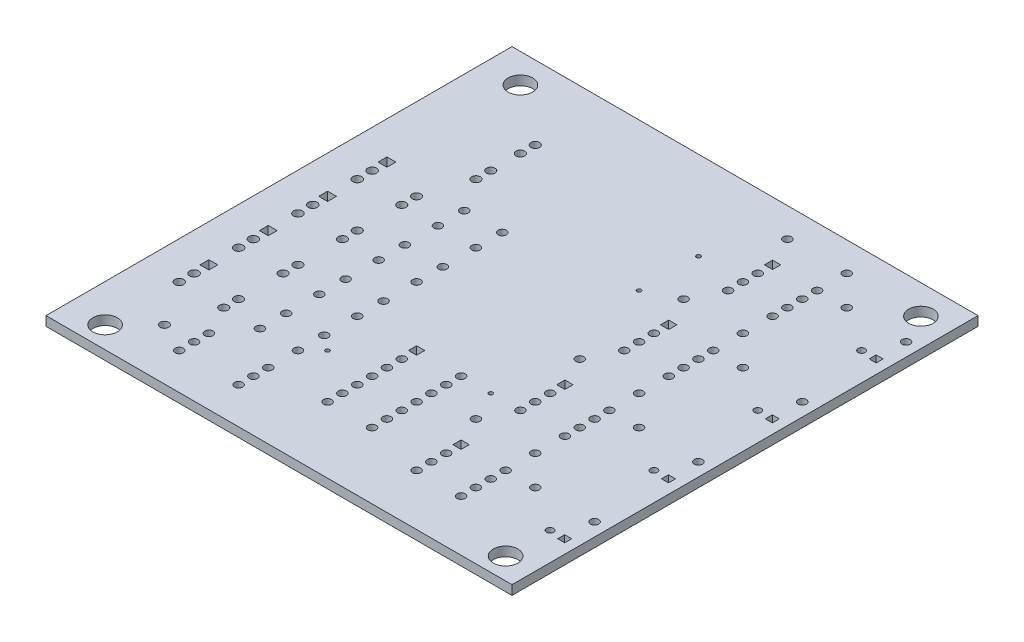
from build123d import *

# Parameters (mm, degrees)
SKETCH1_W           = 79.896668375
SKETCH1_H           = 79.896668375
SKETCH1_R           = 0.699373125
SKETCH1_R_2         = 0.60075445
SKETCH1_R_3         = 0.7629525
SKETCH1_R_4         = 0.73752075
SKETCH1_R_5         = 0.350436799
SKETCH1_R_6         = 2.102626446
SKETCH1_W_2         = 1.39874625
SKETCH1_H_2         = 1.39874625
SKETCH1_W_3         = 1.525905
SKETCH1_H_3         = 1.525905
SKETCH1_W_4         = 1.2015089
SKETCH1_H_4         = 1.2015089
BOSS_EXTRUDE1_DEPTH = 1.6


with BuildPart() as part:
    # Sketch1 → Boss-Extrude1 (new body)
    with BuildSketch(Plane(origin=(0, 1.6, 0), x_dir=(1, 0, 0), z_dir=(0, 1, 0))):
        with Locations((40.050061187, -40.050061187)):
            Rectangle(SKETCH1_W, SKETCH1_H)
        with Locations((26.874260053, -48.901779577)):
            Circle(SKETCH1_R, mode=Mode.SUBTRACT)
        with Locations((54.849220375, -53.407381437)):
            Circle(SKETCH1_R, mode=Mode.SUBTRACT)
        with Locations((26.874260053, -53.407522725)):
            Circle(SKETCH1_R, mode=Mode.SUBTRACT)
        with Locations((75.194408444, -50.864135794)):
            Circle(SKETCH1_R_2, mode=Mode.SUBTRACT)
        with Locations((77.737795375, -45.777856437)):
            Circle(SKETCH1_R, mode=Mode.SUBTRACT)
        with Locations((62.478745375, -40.691506438)):
            Circle(SKETCH1_R, mode=Mode.SUBTRACT)
        with Locations((52.306045375, -40.691506438)):
            Circle(SKETCH1_R, mode=Mode.SUBTRACT)
        with Locations((62.478745375, -53.407381437)):
            Circle(SKETCH1_R, mode=Mode.SUBTRACT)
        with Locations((6.528824731, -61.036906438)):
            Circle(SKETCH1_R_3, mode=Mode.SUBTRACT)
        with Locations((54.849220375, -50.864206437)):
            Circle(SKETCH1_R, mode=Mode.SUBTRACT)
        with Locations((6.528824731, -50.864206437)):
            Circle(SKETCH1_R_3, mode=Mode.SUBTRACT)
        with Locations((62.478745375, -48.321031437)):
            Circle(SKETCH1_R, mode=Mode.SUBTRACT)
        with Locations((54.849220375, -48.321031437)):
            Circle(SKETCH1_R, mode=Mode.SUBTRACT)
        with Locations((62.478745375, -45.777856437)):
            Circle(SKETCH1_R, mode=Mode.SUBTRACT)
        with Locations((6.528824731, -53.407381437)):
            Circle(SKETCH1_R_3, mode=Mode.SUBTRACT)
        with Locations((16.701524731, -20.346177081)):
            Circle(SKETCH1_R_4, mode=Mode.SUBTRACT)
        with Locations((16.701524731, -22.889352081)):
            Circle(SKETCH1_R_4, mode=Mode.SUBTRACT)
        with Locations((29.415043762, -61.060335437)):
            Circle(SKETCH1_R_5, mode=Mode.SUBTRACT)
        with Locations((47.226523093, -15.250971887)):
            Circle(SKETCH1_R_5, mode=Mode.SUBTRACT)
        with Locations((47.226523093, -25.439496087)):
            Circle(SKETCH1_R_5, mode=Mode.SUBTRACT)
        with Locations((67.565095375, -45.777856437)):
            Circle(SKETCH1_R, mode=Mode.SUBTRACT)
        with Locations((6.528824731, -63.580081437)):
            Circle(SKETCH1_R_3, mode=Mode.SUBTRACT)
        with Locations((75.194525006, -5.087088227)):
            Circle(SKETCH1_R_6, mode=Mode.SUBTRACT)
        with Locations((75.194525006, -76.295861068)):
            Circle(SKETCH1_R_6, mode=Mode.SUBTRACT)
        with Locations((20.366006782, -53.407522725)):
            Circle(SKETCH1_R, mode=Mode.SUBTRACT)
        with Locations((6.528800006, -76.295861068)):
            Circle(SKETCH1_R_6, mode=Mode.SUBTRACT)
        with Locations((6.528800006, -5.087088227)):
            Circle(SKETCH1_R_6, mode=Mode.SUBTRACT)
        with Locations((14.158349731, -63.580081437)):
            Circle(SKETCH1_R_4, mode=Mode.SUBTRACT)
        with Locations((6.528824731, -30.518877081)):
            Circle(SKETCH1_R_3, mode=Mode.SUBTRACT)
        with Locations((14.158349731, -50.864206437)):
            Circle(SKETCH1_R_4, mode=Mode.SUBTRACT)
        with Locations((14.158349731, -53.407381437)):
            Circle(SKETCH1_R_4, mode=Mode.SUBTRACT)
        with Locations((14.158349731, -40.691506438)):
            Circle(SKETCH1_R_4, mode=Mode.SUBTRACT)
        with Locations((14.158349731, -43.234681437)):
            Circle(SKETCH1_R_4, mode=Mode.SUBTRACT)
        with Locations((62.478745375, -50.864206437)):
            Circle(SKETCH1_R, mode=Mode.SUBTRACT)
        with Locations((14.158349731, -61.036906438)):
            Circle(SKETCH1_R_4, mode=Mode.SUBTRACT)
        with Locations((14.158349731, -30.518877081)):
            Circle(SKETCH1_R_4, mode=Mode.SUBTRACT)
        with Locations((11.615174731, -71.209606437)):
            Circle(SKETCH1_R_4, mode=Mode.SUBTRACT)
        with Locations((14.158349731, -33.062052081)):
            Circle(SKETCH1_R_4, mode=Mode.SUBTRACT)
        with Locations((16.701524731, -12.716652081)):
            Circle(SKETCH1_R_4, mode=Mode.SUBTRACT)
        with Locations((16.701524731, -15.259827081)):
            Circle(SKETCH1_R_4, mode=Mode.SUBTRACT)
        with Locations((26.874224731, -71.209606437)):
            Circle(SKETCH1_R, mode=Mode.SUBTRACT)
        with Locations((16.701524731, -71.209606437)):
            Circle(SKETCH1_R, mode=Mode.SUBTRACT)
        with Locations((20.366006782, -48.901779577)):
            Circle(SKETCH1_R, mode=Mode.SUBTRACT)
        with Locations((37.046995375, -55.950556437)):
            Circle(SKETCH1_R, mode=Mode.SUBTRACT)
        with Locations((44.676520375, -55.950556437)):
            Circle(SKETCH1_R, mode=Mode.SUBTRACT)
        with Locations((37.046995375, -58.493731438)):
            Circle(SKETCH1_R, mode=Mode.SUBTRACT)
        with Locations((44.676520375, -58.493731438)):
            Circle(SKETCH1_R, mode=Mode.SUBTRACT)
        with Locations((37.046995375, -61.036906438)):
            Circle(SKETCH1_R, mode=Mode.SUBTRACT)
        with Locations((44.676520375, -61.036906438)):
            Circle(SKETCH1_R, mode=Mode.SUBTRACT)
        with Locations((37.046995375, -63.580081437)):
            Circle(SKETCH1_R, mode=Mode.SUBTRACT)
        with Locations((44.676520375, -63.580081437)):
            Circle(SKETCH1_R, mode=Mode.SUBTRACT)
        with Locations((37.046995375, -66.123256437)):
            Circle(SKETCH1_R, mode=Mode.SUBTRACT)
        with Locations((44.676520375, -66.123256437)):
            Circle(SKETCH1_R, mode=Mode.SUBTRACT)
        with Locations((37.046995375, -68.666431437)):
            Circle(SKETCH1_R, mode=Mode.SUBTRACT)
        with Locations((44.676520375, -68.666431437)):
            Circle(SKETCH1_R, mode=Mode.SUBTRACT)
        with Locations((62.478745375, -63.580081437)):
            Circle(SKETCH1_R, mode=Mode.SUBTRACT)
        with Locations((54.849220375, -66.123256437)):
            Circle(SKETCH1_R, mode=Mode.SUBTRACT)
        with Locations((62.478745375, -66.123256437)):
            Circle(SKETCH1_R, mode=Mode.SUBTRACT)
        with Locations((54.849220375, -68.666431437)):
            Circle(SKETCH1_R, mode=Mode.SUBTRACT)
        with Locations((62.478745375, -68.666431437)):
            Circle(SKETCH1_R, mode=Mode.SUBTRACT)
        with Locations((54.849220375, -71.209606437)):
            Circle(SKETCH1_R, mode=Mode.SUBTRACT)
        with Locations((62.478745375, -71.209606437)):
            Circle(SKETCH1_R, mode=Mode.SUBTRACT)
        with Locations((52.306045375, -58.493731438)):
            Circle(SKETCH1_R, mode=Mode.SUBTRACT)
        with Locations((62.478745375, -58.493731438)):
            Circle(SKETCH1_R, mode=Mode.SUBTRACT)
        with Locations((16.701524731, -73.752781437)):
            Circle(SKETCH1_R, mode=Mode.SUBTRACT)
        with Locations((26.874224731, -73.752781437)):
            Circle(SKETCH1_R, mode=Mode.SUBTRACT)
        with Locations((62.478745375, -27.975702081)):
            Circle(SKETCH1_R, mode=Mode.SUBTRACT)
        with Locations((54.849220375, -30.518877081)):
            Circle(SKETCH1_R, mode=Mode.SUBTRACT)
        with Locations((62.478745375, -30.518877081)):
            Circle(SKETCH1_R, mode=Mode.SUBTRACT)
        with Locations((54.849220375, -33.062052081)):
            Circle(SKETCH1_R, mode=Mode.SUBTRACT)
        with Locations((62.478745375, -33.062052081)):
            Circle(SKETCH1_R, mode=Mode.SUBTRACT)
        with Locations((54.849220375, -35.605227081)):
            Circle(SKETCH1_R, mode=Mode.SUBTRACT)
        with Locations((62.478745375, -35.605227081)):
            Circle(SKETCH1_R, mode=Mode.SUBTRACT)
        with Locations((52.306045375, -22.889352081)):
            Circle(SKETCH1_R, mode=Mode.SUBTRACT)
        with Locations((62.478745375, -22.889352081)):
            Circle(SKETCH1_R, mode=Mode.SUBTRACT)
        with Locations((62.478745375, -10.173477081)):
            Circle(SKETCH1_R, mode=Mode.SUBTRACT)
        with Locations((54.849220375, -12.716652081)):
            Circle(SKETCH1_R, mode=Mode.SUBTRACT)
        with Locations((62.478745375, -12.716652081)):
            Circle(SKETCH1_R, mode=Mode.SUBTRACT)
        with Locations((54.849220375, -15.259827081)):
            Circle(SKETCH1_R, mode=Mode.SUBTRACT)
        with Locations((62.478745375, -15.259827081)):
            Circle(SKETCH1_R, mode=Mode.SUBTRACT)
        with Locations((54.849220375, -17.803002081)):
            Circle(SKETCH1_R, mode=Mode.SUBTRACT)
        with Locations((62.478745375, -17.803002081)):
            Circle(SKETCH1_R, mode=Mode.SUBTRACT)
        with Locations((52.306045375, -5.087127081)):
            Circle(SKETCH1_R, mode=Mode.SUBTRACT)
        with Locations((62.478745375, -5.087127081)):
            Circle(SKETCH1_R, mode=Mode.SUBTRACT)
        with Locations((26.874224731, -68.666431437)):
            Circle(SKETCH1_R, mode=Mode.SUBTRACT)
        with Locations((16.701524731, -68.666431437)):
            Circle(SKETCH1_R, mode=Mode.SUBTRACT)
        with Locations((75.194408444, -15.259827081)):
            Circle(SKETCH1_R_2, mode=Mode.SUBTRACT)
        with Locations((75.194408444, -68.666360794)):
            Circle(SKETCH1_R_2, mode=Mode.SUBTRACT)
        with Locations((75.194408444, -33.061910794)):
            Circle(SKETCH1_R_2, mode=Mode.SUBTRACT)
        with Locations((26.874260053, -63.580222725)):
            Circle(SKETCH1_R, mode=Mode.SUBTRACT)
        with Locations((20.366006782, -63.580222725)):
            Circle(SKETCH1_R, mode=Mode.SUBTRACT)
        with Locations((26.874260053, -59.074479577)):
            Circle(SKETCH1_R, mode=Mode.SUBTRACT)
        with Locations((20.366006782, -59.074479577)):
            Circle(SKETCH1_R, mode=Mode.SUBTRACT)
        with Locations((26.874260053, -43.234822725)):
            Circle(SKETCH1_R, mode=Mode.SUBTRACT)
        with Locations((20.366006782, -43.234822725)):
            Circle(SKETCH1_R, mode=Mode.SUBTRACT)
        with Locations((26.874260053, -38.729079578)):
            Circle(SKETCH1_R, mode=Mode.SUBTRACT)
        with Locations((20.366006782, -38.729079578)):
            Circle(SKETCH1_R, mode=Mode.SUBTRACT)
        with Locations((26.874260053, -33.062052081)):
            Circle(SKETCH1_R, mode=Mode.SUBTRACT)
        with Locations((20.366006782, -33.062052081)):
            Circle(SKETCH1_R, mode=Mode.SUBTRACT)
        with Locations((6.528824731, -33.062052081)):
            Circle(SKETCH1_R_3, mode=Mode.SUBTRACT)
        with Locations((6.528824731, -40.691506438)):
            Circle(SKETCH1_R_3, mode=Mode.SUBTRACT)
        with Locations((6.528824731, -43.234681437)):
            Circle(SKETCH1_R_3, mode=Mode.SUBTRACT)
        with Locations((49.769344875, -53.407144781)):
            Circle(SKETCH1_R_5, mode=Mode.SUBTRACT)
        with Locations((44.676520375, -53.407381437)):
            Circle(SKETCH1_R, mode=Mode.SUBTRACT)
        with Locations((77.737795375, -10.173477081)):
            Circle(SKETCH1_R, mode=Mode.SUBTRACT)
        with Locations((67.565095375, -10.173477081)):
            Circle(SKETCH1_R, mode=Mode.SUBTRACT)
        with Locations((77.737795375, -27.975702081)):
            Circle(SKETCH1_R, mode=Mode.SUBTRACT)
        with Locations((67.565095375, -27.975702081)):
            Circle(SKETCH1_R, mode=Mode.SUBTRACT)
        with Locations((77.737795375, -63.580081437)):
            Circle(SKETCH1_R, mode=Mode.SUBTRACT)
        with Locations((67.565095375, -63.580081437)):
            Circle(SKETCH1_R, mode=Mode.SUBTRACT)
        with Locations((20.366006782, -28.556308934)):
            Circle(SKETCH1_R, mode=Mode.SUBTRACT)
        with Locations((26.874260053, -28.556308934)):
            Circle(SKETCH1_R, mode=Mode.SUBTRACT)
        with Locations((54.849220375, -45.777856437)):
            Rectangle(SKETCH1_W_2, SKETCH1_H_2, mode=Mode.SUBTRACT)
        with Locations((6.528824731, -38.148331438)):
            Rectangle(SKETCH1_W_3, SKETCH1_H_3, mode=Mode.SUBTRACT)
        with Locations((6.528824731, -58.493731438)):
            Rectangle(SKETCH1_W_3, SKETCH1_H_3, mode=Mode.SUBTRACT)
        with Locations((6.528824731, -27.975702081)):
            Rectangle(SKETCH1_W_3, SKETCH1_H_3, mode=Mode.SUBTRACT)
        with Locations((77.697740369, -50.864135794)):
            Rectangle(SKETCH1_W_4, SKETCH1_H_4, mode=Mode.SUBTRACT)
        with Locations((37.046995375, -53.407381438)):
            Rectangle(SKETCH1_W_2, SKETCH1_H_2, mode=Mode.SUBTRACT)
        with Locations((6.528824731, -48.321031438)):
            Rectangle(SKETCH1_W_3, SKETCH1_H_3, mode=Mode.SUBTRACT)
        with Locations((54.849220375, -63.580081437)):
            Rectangle(SKETCH1_W_2, SKETCH1_H_2, mode=Mode.SUBTRACT)
        with Locations((54.849220375, -27.975702081)):
            Rectangle(SKETCH1_W_2, SKETCH1_H_2, mode=Mode.SUBTRACT)
        with Locations((54.849220375, -10.173477081)):
            Rectangle(SKETCH1_W_2, SKETCH1_H_2, mode=Mode.SUBTRACT)
        with Locations((77.697740369, -15.259827081)):
            Rectangle(SKETCH1_W_4, SKETCH1_H_4, mode=Mode.SUBTRACT)
        with Locations((77.697740369, -68.666360794)):
            Rectangle(SKETCH1_W_4, SKETCH1_H_4, mode=Mode.SUBTRACT)
        with Locations((77.697740369, -33.061910794)):
            Rectangle(SKETCH1_W_4, SKETCH1_H_4, mode=Mode.SUBTRACT)
    extrude(amount=-BOSS_EXTRUDE1_DEPTH)


solid = part.part
